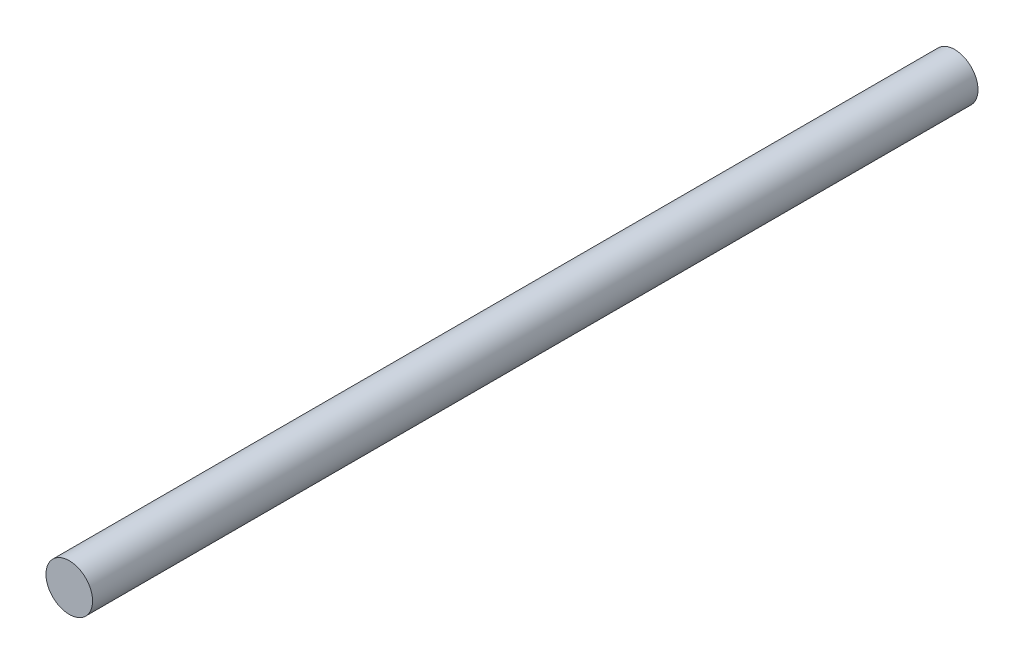
from build123d import *

# Parameters (mm, degrees)
SKETCH1_R           = 1.5
BOSS_EXTRUDE1_DEPTH = 57


with BuildPart() as part:
    # Sketch1 → Boss-Extrude1 (new body)
    with BuildSketch(Plane.XY):
        Circle(SKETCH1_R)
    extrude(amount=BOSS_EXTRUDE1_DEPTH)


solid = part.part
